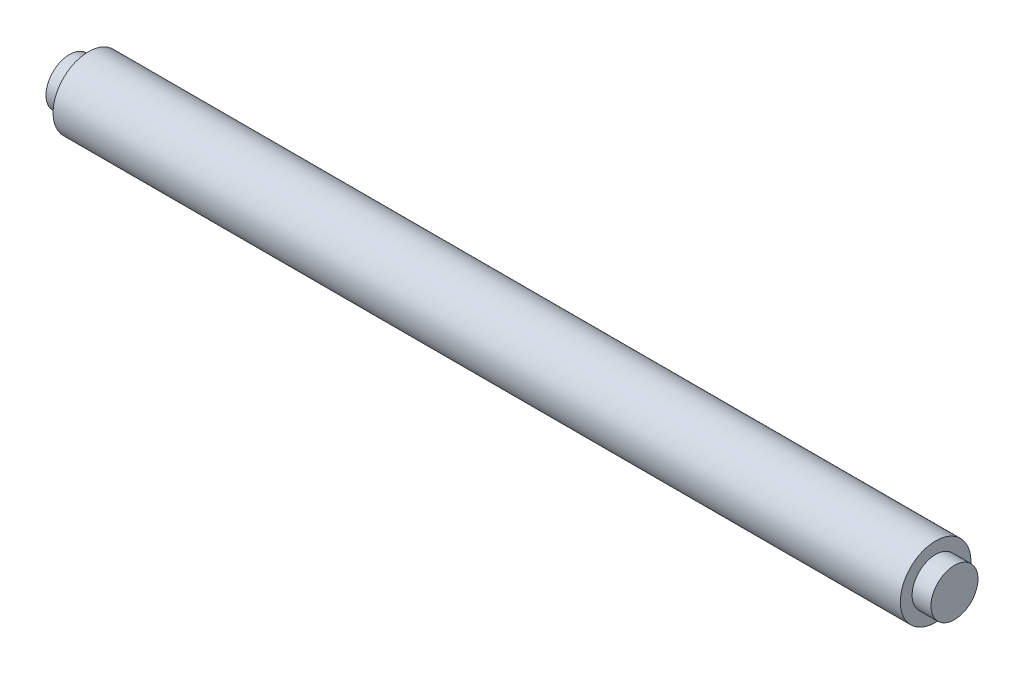
from build123d import *

# Parameters (mm, degrees)
SKETCH1_R           = 0.75
BOSS_EXTRUDE1_DEPTH = 18
SKETCH2_R           = 0.5
BOSS_EXTRUDE2_DEPTH = 0.4
SKETCH3_R           = 0.5
BOSS_EXTRUDE3_DEPTH = 0.4


with BuildPart() as part:
    # Sketch1 → Boss-Extrude1 (new body)
    with BuildSketch(Plane(origin=(0, 0, 0), x_dir=(0, 0, -1), z_dir=(1, 0, 0))):
        Circle(SKETCH1_R)
    extrude(amount=BOSS_EXTRUDE1_DEPTH)

    # Sketch2 → Boss-Extrude2 (add)
    with BuildSketch(Plane(origin=(18, 0, 0), x_dir=(0, 0, -1), z_dir=(1, 0, 0))):
        Circle(SKETCH2_R)
    extrude(amount=BOSS_EXTRUDE2_DEPTH)

    # Sketch3 → Boss-Extrude3 (add)
    with BuildSketch(Plane.ZY):
        Circle(SKETCH3_R)
    extrude(amount=BOSS_EXTRUDE3_DEPTH)


solid = part.part
